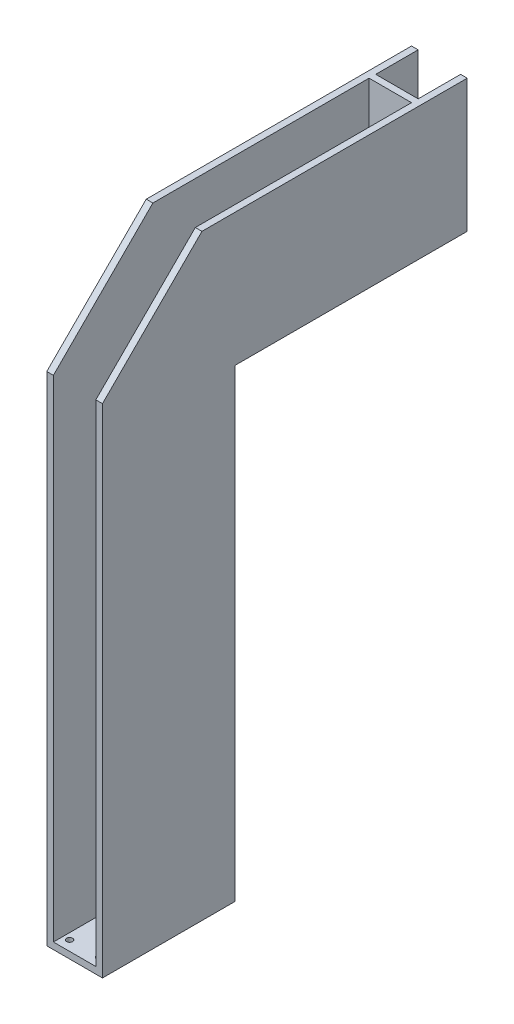
from build123d import *

# Parameters (mm, degrees)
BOSS_EXTRUDE1_DEPTH      = 10
BOSS_EXTRUDE1_DEPTH_BACK = 74
SKETCH3_W                = 64
SKETCH3_H                = 550
CUT_EXTRUDE1_DEPTH       = 890
SKETCH4_W                = 64
SKETCH4_H                = 350
BOSS_EXTRUDE2_DEPTH      = 10
SKETCH5_W                = 64
SKETCH5_H                = 190
BOSS_EXTRUDE3_DEPTH      = 10
CUT_EXTRUDE2_REACH       = 712
SKETCH6_R                = 4.5
CUT_EXTRUDE3_REACH       = 76
SKETCH7_R                = 8
CUT_EXTRUDE4_REACH       = 12
SKETCH8_R                = 4.5
SKETCH8_R_2              = 5


with BuildPart() as part:
    # Sketch1 → Boss-Extrude1 (new body, two sides)
    with BuildSketch(Plane(origin=(0, 0, 0), x_dir=(0, 0, -1), z_dir=(1, 0, 0))) as boss_extrude1_sk:
        Polygon((0, 0), (0, 750), (150, 900), (550, 900), (550, 700), (200, 700), (200, 0), align=None)
    extrude(amount=BOSS_EXTRUDE1_DEPTH)
    extrude(boss_extrude1_sk.sketch, amount=-BOSS_EXTRUDE1_DEPTH_BACK)

    # Sketch3 → Cut-Extrude1 (cut)
    with BuildSketch(Plane(origin=(0, 900, 0), x_dir=(1, 0, 0), z_dir=(0, 1, 0))):
        with Locations((-32, 275)):
            Rectangle(SKETCH3_W, SKETCH3_H)
    extrude(amount=-CUT_EXTRUDE1_DEPTH, mode=Mode.SUBTRACT)

    # Sketch4 → Boss-Extrude2 (add)
    with BuildSketch(Plane.XZ.offset(-700)):
        with Locations((-32, -375)):
            Rectangle(SKETCH4_W, SKETCH4_H)
    extrude(amount=-BOSS_EXTRUDE2_DEPTH)

    # Sketch5 → Boss-Extrude3 (add)
    with BuildSketch(Plane(origin=(0, 0, -486), x_dir=(-1, 0, 0), z_dir=(0, 0, -1))):
        with Locations((32, 805)):
            Rectangle(SKETCH5_W, SKETCH5_H)
    extrude(amount=-BOSS_EXTRUDE3_DEPTH)

    # Sketch6 → Cut-Extrude2 (cut, up to next)
    with BuildSketch(Plane(origin=(0, 710, 0), x_dir=(1, 0, 0), z_dir=(0, 1, 0)), mode=Mode.PRIVATE) as cut_extrude2_sk1:
        with Locations((-8.5, 494.5)):
            Circle(SKETCH6_R)
    cut_extrude2_tool1 = extrude(cut_extrude2_sk1.sketch, amount=-CUT_EXTRUDE2_REACH, mode=Mode.PRIVATE) & part.part
    add(cut_extrude2_tool1.solids().sort_by_distance((-8.5, 710, -494.5))[0], mode=Mode.SUBTRACT)
    # Sketch6 → Cut-Extrude2 (cut, up to next)
    with BuildSketch(Plane(origin=(0, 710, 0), x_dir=(1, 0, 0), z_dir=(0, 1, 0)), mode=Mode.PRIVATE) as cut_extrude2_sk2:
        with Locations((-55, 494.5)):
            Circle(SKETCH6_R)
    cut_extrude2_tool2 = extrude(cut_extrude2_sk2.sketch, amount=-CUT_EXTRUDE2_REACH, mode=Mode.PRIVATE) & part.part
    add(cut_extrude2_tool2.solids().sort_by_distance((-55, 710, -494.5))[0], mode=Mode.SUBTRACT)
    # Sketch6 → Cut-Extrude2 (cut, up to next)
    with BuildSketch(Plane(origin=(0, 710, 0), x_dir=(1, 0, 0), z_dir=(0, 1, 0)), mode=Mode.PRIVATE) as cut_extrude2_sk3:
        with Locations((-55, 541)):
            Circle(SKETCH6_R)
    cut_extrude2_tool3 = extrude(cut_extrude2_sk3.sketch, amount=-CUT_EXTRUDE2_REACH, mode=Mode.PRIVATE) & part.part
    add(cut_extrude2_tool3.solids().sort_by_distance((-55, 710, -541))[0], mode=Mode.SUBTRACT)
    # Sketch6 → Cut-Extrude2 (cut, up to next)
    with BuildSketch(Plane(origin=(0, 710, 0), x_dir=(1, 0, 0), z_dir=(0, 1, 0)), mode=Mode.PRIVATE) as cut_extrude2_sk4:
        with Locations((-8.5, 541)):
            Circle(SKETCH6_R)
    cut_extrude2_tool4 = extrude(cut_extrude2_sk4.sketch, amount=-CUT_EXTRUDE2_REACH, mode=Mode.PRIVATE) & part.part
    add(cut_extrude2_tool4.solids().sort_by_distance((-8.5, 710, -541))[0], mode=Mode.SUBTRACT)

    # Sketch7 → Cut-Extrude3 (cut, up to next)
    with BuildSketch(Plane.XY.offset(-476), mode=Mode.PRIVATE) as cut_extrude3_sk1:
        with Locations((-26.25, 732.5)):
            Circle(SKETCH7_R)
    cut_extrude3_tool1 = extrude(cut_extrude3_sk1.sketch, amount=-CUT_EXTRUDE3_REACH, mode=Mode.PRIVATE) & part.part
    add(cut_extrude3_tool1.solids().sort_by_distance((-26.25, 732.5, -476))[0], mode=Mode.SUBTRACT)

    # Sketch8 → Cut-Extrude4 (cut, up to next)
    with BuildSketch(Plane(origin=(0, 10, 0), x_dir=(1, 0, 0), z_dir=(0, 1, 0)), mode=Mode.PRIVATE) as cut_extrude4_sk1:
        with Locations((-54.5, 185)):
            Circle(SKETCH8_R)
    cut_extrude4_tool1 = extrude(cut_extrude4_sk1.sketch, amount=-CUT_EXTRUDE4_REACH, mode=Mode.PRIVATE) & part.part
    add(cut_extrude4_tool1.solids().sort_by_distance((-54.5, 10, -185))[0], mode=Mode.SUBTRACT)
    # Sketch8 → Cut-Extrude4 (cut, up to next)
    with BuildSketch(Plane(origin=(0, 10, 0), x_dir=(1, 0, 0), z_dir=(0, 1, 0)), mode=Mode.PRIVATE) as cut_extrude4_sk2:
        with Locations((-54.5, 165)):
            Circle(SKETCH8_R_2)
    cut_extrude4_tool2 = extrude(cut_extrude4_sk2.sketch, amount=-CUT_EXTRUDE4_REACH, mode=Mode.PRIVATE) & part.part
    add(cut_extrude4_tool2.solids().sort_by_distance((-54.5, 10, -165))[0], mode=Mode.SUBTRACT)
    # Sketch8 → Cut-Extrude4 (cut, up to next)
    with BuildSketch(Plane(origin=(0, 10, 0), x_dir=(1, 0, 0), z_dir=(0, 1, 0)), mode=Mode.PRIVATE) as cut_extrude4_sk3:
        with Locations((-54.5, 15)):
            Circle(SKETCH8_R)
    cut_extrude4_tool3 = extrude(cut_extrude4_sk3.sketch, amount=-CUT_EXTRUDE4_REACH, mode=Mode.PRIVATE) & part.part
    add(cut_extrude4_tool3.solids().sort_by_distance((-54.5, 10, -15))[0], mode=Mode.SUBTRACT)
    # Sketch8 → Cut-Extrude4 (cut, up to next)
    with BuildSketch(Plane(origin=(0, 10, 0), x_dir=(1, 0, 0), z_dir=(0, 1, 0)), mode=Mode.PRIVATE) as cut_extrude4_sk4:
        with Locations((-9.5, 15)):
            Circle(SKETCH8_R)
    cut_extrude4_tool4 = extrude(cut_extrude4_sk4.sketch, amount=-CUT_EXTRUDE4_REACH, mode=Mode.PRIVATE) & part.part
    add(cut_extrude4_tool4.solids().sort_by_distance((-9.5, 10, -15))[0], mode=Mode.SUBTRACT)
    # Sketch8 → Cut-Extrude4 (cut, up to next)
    with BuildSketch(Plane(origin=(0, 10, 0), x_dir=(1, 0, 0), z_dir=(0, 1, 0)), mode=Mode.PRIVATE) as cut_extrude4_sk5:
        with Locations((-9.5, 35)):
            Circle(SKETCH8_R_2)
    cut_extrude4_tool5 = extrude(cut_extrude4_sk5.sketch, amount=-CUT_EXTRUDE4_REACH, mode=Mode.PRIVATE) & part.part
    add(cut_extrude4_tool5.solids().sort_by_distance((-9.5, 10, -35))[0], mode=Mode.SUBTRACT)
    # Sketch8 → Cut-Extrude4 (cut, up to next)
    with BuildSketch(Plane(origin=(0, 10, 0), x_dir=(1, 0, 0), z_dir=(0, 1, 0)), mode=Mode.PRIVATE) as cut_extrude4_sk6:
        with Locations((-9.5, 185)):
            Circle(SKETCH8_R)
    cut_extrude4_tool6 = extrude(cut_extrude4_sk6.sketch, amount=-CUT_EXTRUDE4_REACH, mode=Mode.PRIVATE) & part.part
    add(cut_extrude4_tool6.solids().sort_by_distance((-9.5, 10, -185))[0], mode=Mode.SUBTRACT)


solid = part.part
